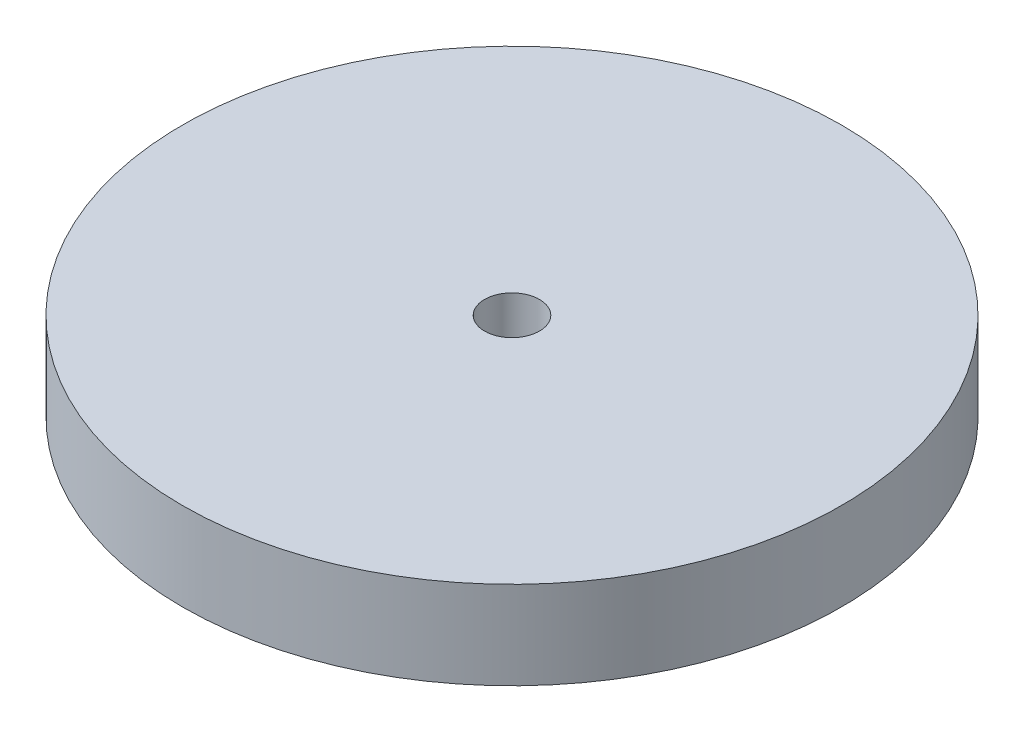
from build123d import *

# Parameters (mm, degrees)
SKETCH1_R           = 30
BOSS_EXTRUDE1_DEPTH = 8
SKETCH2_R           = 2.5
CUT_EXTRUDE1_DEPTH  = 10


with BuildPart() as part:
    # Sketch1 → Boss-Extrude1 (new body)
    with BuildSketch(Plane(origin=(0, 0, 0), x_dir=(1, 0, 0), z_dir=(0, 1, 0))):
        Circle(SKETCH1_R)
    extrude(amount=BOSS_EXTRUDE1_DEPTH)

    # Sketch2 → Cut-Extrude1 (cut)
    with BuildSketch(Plane(origin=(0, 8, 0), x_dir=(1, 0, 0), z_dir=(0, 1, 0))):
        Circle(SKETCH2_R)
    extrude(amount=-CUT_EXTRUDE1_DEPTH, mode=Mode.SUBTRACT)


solid = part.part
